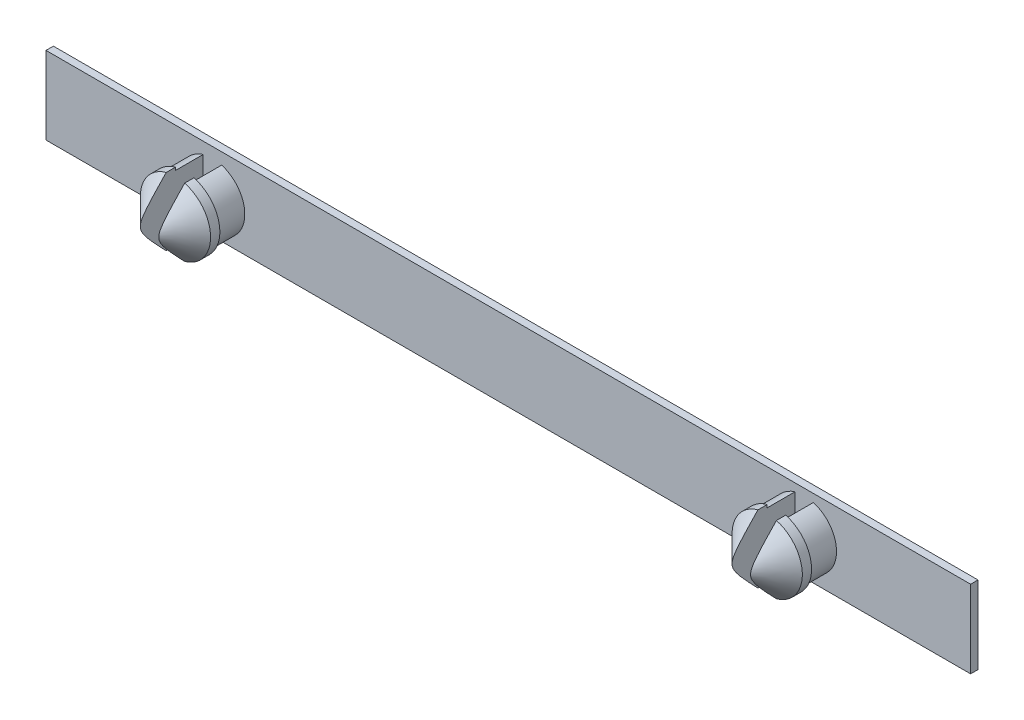
from build123d import *

# Parameters (mm, degrees)
SKICA2_W                 = 50
SKICA2_H                 = 4.2
P_IDAT_VYSUNUT_M2_DEPTH  = 0.4
SKICA3_R                 = 1.75
P_IDAT_VYSUNUT_M3_DEPTH  = 1.5
SKICA5_R                 = 1.9
P_IDAT_VYSUNUT_M5_DEPTH  = 2
ZKOSEN_2_SIZE            = 1.5
SKICA7_W                 = 1
SKICA7_H                 = 5
ODEBRAT_VYSUNUT_M1_DEPTH = 3.5


with BuildPart() as part:
    # Skica2 → Přidat vysunutím2 (new body)
    with BuildSketch(Plane.XY):
        Rectangle(SKICA2_W, SKICA2_H)
    extrude(amount=P_IDAT_VYSUNUT_M2_DEPTH)

    # Skica3 → Přidat vysunutím3 (add)
    with BuildSketch(Plane.XY.offset(0.4)):
        with Locations((-16, -0.2)):
            Circle(SKICA3_R)
        with Locations((16, 0)):
            Circle(SKICA3_R)
    extrude(amount=P_IDAT_VYSUNUT_M3_DEPTH)

    # Skica5 → Přidat vysunutím5 (add)
    with BuildSketch(Plane.XY.offset(1.9)):
        with Locations((-16, -0.2)):
            Circle(SKICA5_R)
        with Locations((16, 0)):
            Circle(SKICA5_R)
    extrude(amount=P_IDAT_VYSUNUT_M5_DEPTH)

    # Zkosení2
    zkosen_2_edges = [part.edges().sort_by_distance(p)[0] for p in [
        (-17.9, -0.2, 3.9),
        (14.1, 0, 3.9),
    ]]
    chamfer(zkosen_2_edges, length=ZKOSEN_2_SIZE)

    # Skica7 → Odebrat vysunutím1 (cut)
    with BuildSketch(Plane.XY.offset(3.9)):
        with Locations((-16, -0.2)):
            Rectangle(SKICA7_W, SKICA7_H)
        with Locations((16, 0)):
            Rectangle(SKICA7_W, SKICA7_H)
    extrude(amount=-ODEBRAT_VYSUNUT_M1_DEPTH, mode=Mode.SUBTRACT)


solid = part.part
